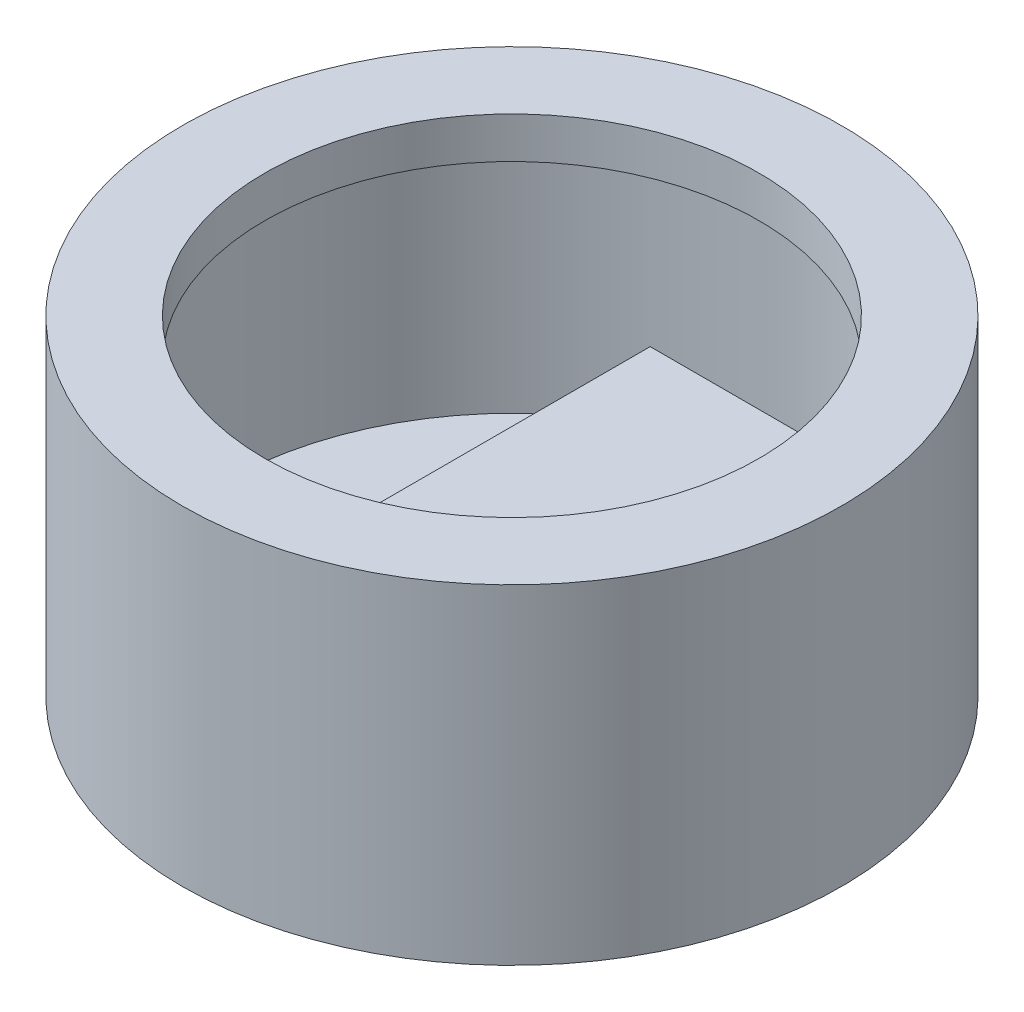
from build123d import *

# Parameters (mm, degrees)
SKETCH2_R               = 40
HOUSING_DEPTH           = 40
SKETCH11_R              = 30
EXTERNALCUT_DEPTH       = 35
INTERNALCUT_START       = -5
SKETCH12_R              = 35
INTERNALCUT_DEPTH       = 30
SKETCH18_W              = 27.94
SKETCH18_H              = 52.97706376
ESP32_DEPTH             = 9.74
SKETCH19_R              = 6
BUZZERINTERNALCUT_DEPTH = 2
SKETCH20_R              = 0.35
BUZZEREXTRENALCUT_DEPTH = 4
SKETCH22_W              = 4.6
SKETCH22_H              = 6.1
BTNITERNALCUT_DEPTH     = 2
SKETCH25_R              = 1.5
BTNEXTRERNALCUT_DEPTH   = 4
SKETCH26_W              = 3.7
SKETCH26_H              = 8.5
CUT_EXTRUDE6_DEPTH      = 2
SKETCH28_W              = 1.7
SKETCH28_H              = 3.6
CUT_EXTRUDE7_DEPTH      = 4


with BuildPart() as part:
    # Sketch2 → Housing (new body)
    with BuildSketch(Plane(origin=(0, 0, 0), x_dir=(1, 0, 0), z_dir=(0, 1, 0))):
        Circle(SKETCH2_R)
    extrude(amount=HOUSING_DEPTH)

    # Sketch11 → ExternalCUt (cut)
    with BuildSketch(Plane(origin=(0, 40, 0), x_dir=(1, 0, 0), z_dir=(0, 1, 0))):
        Circle(SKETCH11_R)
    extrude(amount=-EXTERNALCUT_DEPTH, mode=Mode.SUBTRACT)

    # Sketch12 → InternalCut (cut)
    with BuildSketch(Plane.XZ.offset(INTERNALCUT_START)):
        Circle(SKETCH12_R)
    extrude(amount=-INTERNALCUT_DEPTH, mode=Mode.SUBTRACT)

    # Sketch18 → ESP32 (add)
    with BuildSketch(Plane(origin=(0, 5, 0), x_dir=(1, 0, 0), z_dir=(0, 1, 0))):
        with Locations((0.343820119, 3.916007291)):
            Rectangle(SKETCH18_W, SKETCH18_H)
    extrude(amount=ESP32_DEPTH)

    # Sketch19 → BuzzerInternalCut (cut)
    with BuildSketch(Plane(origin=(0, 5, 0), x_dir=(1, 0, 0), z_dir=(0, 1, 0))):
        with Locations((-25.006618322, 0)):
            Circle(SKETCH19_R)
    extrude(amount=-BUZZERINTERNALCUT_DEPTH, mode=Mode.SUBTRACT)

    # Sketch20 → BuzzerExtrenalCut (cut, through all)
    with BuildSketch(Plane(origin=(0, 3, 0), x_dir=(1, 0, 0), z_dir=(0, 1, 0))):
        with Locations((-24.042348329, 4.522315504)):
            Circle(SKETCH20_R)
        with Locations((-26.042348329, 3.020429056)):
            Circle(SKETCH20_R)
        with Locations((-28.042348329, 3.020429056)):
            Circle(SKETCH20_R)
        with Locations((-30.042348329, 1.518542609)):
            Circle(SKETCH20_R)
        with Locations((-30.042348329, 0.016656161)):
            Circle(SKETCH20_R)
        with Locations((-30.042348329, -1.485230286)):
            Circle(SKETCH20_R)
        with Locations((-28.042348329, 0.016656161)):
            Circle(SKETCH20_R)
        with Locations((-28.042348329, 1.518542609)):
            Circle(SKETCH20_R)
        with Locations((-28.042348329, -1.485230286)):
            Circle(SKETCH20_R)
        with Locations((-28.042348329, -2.987116733)):
            Circle(SKETCH20_R)
        with Locations((-26.042348329, 0.016656161)):
            Circle(SKETCH20_R)
        with Locations((-26.042348329, 1.518542609)):
            Circle(SKETCH20_R)
        with Locations((-26.042348329, -1.485230286)):
            Circle(SKETCH20_R)
        with Locations((-26.042348329, -2.987116733)):
            Circle(SKETCH20_R)
        with Locations((-26.042348329, -4.489003181)):
            Circle(SKETCH20_R)
        with Locations((-24.042348329, -4.489003181)):
            Circle(SKETCH20_R)
        with Locations((-24.042348329, -2.987116733)):
            Circle(SKETCH20_R)
        with Locations((-24.042348329, -1.485230286)):
            Circle(SKETCH20_R)
        with Locations((-24.042348329, 0.016656161)):
            Circle(SKETCH20_R)
        with Locations((-24.042348329, 1.518542609)):
            Circle(SKETCH20_R)
        with Locations((-24.042348329, 3.020429056)):
            Circle(SKETCH20_R)
        with Locations((-22.042348329, 3.020429056)):
            Circle(SKETCH20_R)
        with Locations((-22.042348329, 1.518542609)):
            Circle(SKETCH20_R)
        with Locations((-22.042348329, 0.016656161)):
            Circle(SKETCH20_R)
        with Locations((-22.042348329, -1.485230286)):
            Circle(SKETCH20_R)
        with Locations((-22.042348329, -2.987116733)):
            Circle(SKETCH20_R)
        with Locations((-20.042348329, -1.485230286)):
            Circle(SKETCH20_R)
        with Locations((-20.042348329, 0.016656161)):
            Circle(SKETCH20_R)
        with Locations((-20.042348329, 1.518542609)):
            Circle(SKETCH20_R)
        with Locations((-26.042348329, 4.522315504)):
            Circle(SKETCH20_R)
    extrude(amount=-BUZZEREXTRENALCUT_DEPTH, mode=Mode.SUBTRACT)

    # Sketch22 → BtnIternalCut (cut)
    with BuildSketch(Plane(origin=(0, 5, 0), x_dir=(1, 0, 0), z_dir=(0, 1, 0))):
        with Locations((23.28859565, -11.93832654)):
            Rectangle(SKETCH22_W, SKETCH22_H)
    extrude(amount=-BTNITERNALCUT_DEPTH, mode=Mode.SUBTRACT)

    # Sketch25 → BtnExtrernalCut (cut, through all)
    with BuildSketch(Plane(origin=(0, 3, 0), x_dir=(1, 0, 0), z_dir=(0, 1, 0))):
        with Locations((23.28859565, -11.93832654)):
            Circle(SKETCH25_R)
    extrude(amount=-BTNEXTRERNALCUT_DEPTH, mode=Mode.SUBTRACT)

    # Sketch26 → Cut-Extrude6 (cut)
    with BuildSketch(Plane(origin=(0, 5, 0), x_dir=(1, 0, 0), z_dir=(0, 1, 0))):
        with Locations((23.409044431, 13.599064282)):
            Rectangle(SKETCH26_W, SKETCH26_H)
    extrude(amount=-CUT_EXTRUDE6_DEPTH, mode=Mode.SUBTRACT)

    # Sketch28 → Cut-Extrude7 (cut, through all)
    with BuildSketch(Plane(origin=(0, 3, 0), x_dir=(1, 0, 0), z_dir=(0, 1, 0))):
        with Locations((23.409044431, 13.599064282)):
            Rectangle(SKETCH28_W, SKETCH28_H)
    extrude(amount=-CUT_EXTRUDE7_DEPTH, mode=Mode.SUBTRACT)


solid = part.part
